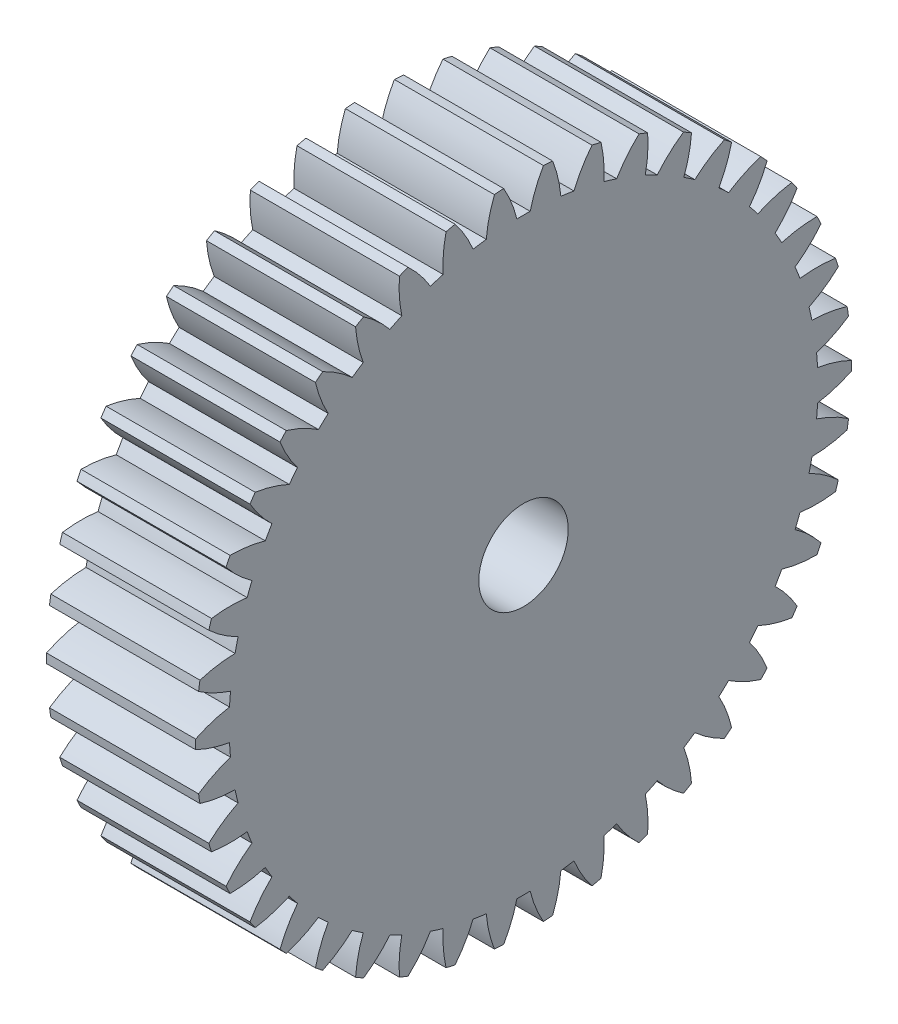
from build123d import *

# Parameters (mm, degrees)
BASPROSKE_W     = 10
BASPROSKE_H     = 22
TOOTHCUT_DEPTH  = 33.680269277
TEETHCUTS_COUNT = 42
TEETHCUTS_ANGLE = 351.428571429
BORSKE_R        = 3
BORE_DEPTH      = 50.0000508


with BuildPart() as part:
    # BasProSke → Base-Revolve (revolve)
    with BuildSketch(Plane(origin=(0, 0, 0), x_dir=(1, 0, 0), z_dir=(0, 1, 0)), mode=Mode.PRIVATE) as base_revolve_sk:
        with Locations((5, 11)):
            Rectangle(BASPROSKE_W, BASPROSKE_H)
    revolve(base_revolve_sk.sketch.rotate(Axis((-10, 0, 0), (1, 0, 0)), 180), axis=Axis((-10, 0, 0), (1, 0, 0)))

    # TooCutSke → ToothCut (cut, through all)
    with BuildSketch(Plane(origin=(0, 0, 0), x_dir=(0, 0, -1), z_dir=(1, 0, 0))):
        with BuildLine():
            ThreePointArc((0.446078735, 19.743961476), (0, 19.749), (-0.446078735, 19.743961476))
            ThreePointArc((-0.446078735, 19.743961476), (-0.816459964, 20.896623713), (-1.348697399, 21.984068333))
            ThreePointArc((-1.348697399, 21.984068333), (0, 22.0254), (1.348697399, 21.984068333))
            ThreePointArc((1.348697399, 21.984068333), (0.816459964, 20.896623713), (0.446078735, 19.743961476))
        make_face()
    toothcut = extrude(amount=TOOTHCUT_DEPTH, mode=Mode.SUBTRACT)

    # TeethCuts: ToothCut ×42 about axis
    teethcuts_axis = Axis((-10, 0, 0), (1, 0, 0))
    for i in range(1, TEETHCUTS_COUNT):
        add(toothcut.rotate(teethcuts_axis, i * TEETHCUTS_ANGLE / (TEETHCUTS_COUNT - 1)), mode=Mode.SUBTRACT)

    # BorSke → Bore (cut, symmetric)
    with BuildSketch(Plane(origin=(0, 0, 0), x_dir=(0, 0, -1), z_dir=(1, 0, 0))):
        with Locations(Location((0, 0, 0), (0, 0, 180))):
            Circle(BORSKE_R)
    extrude(amount=BORE_DEPTH, both=True, mode=Mode.SUBTRACT)


solid = part.part
